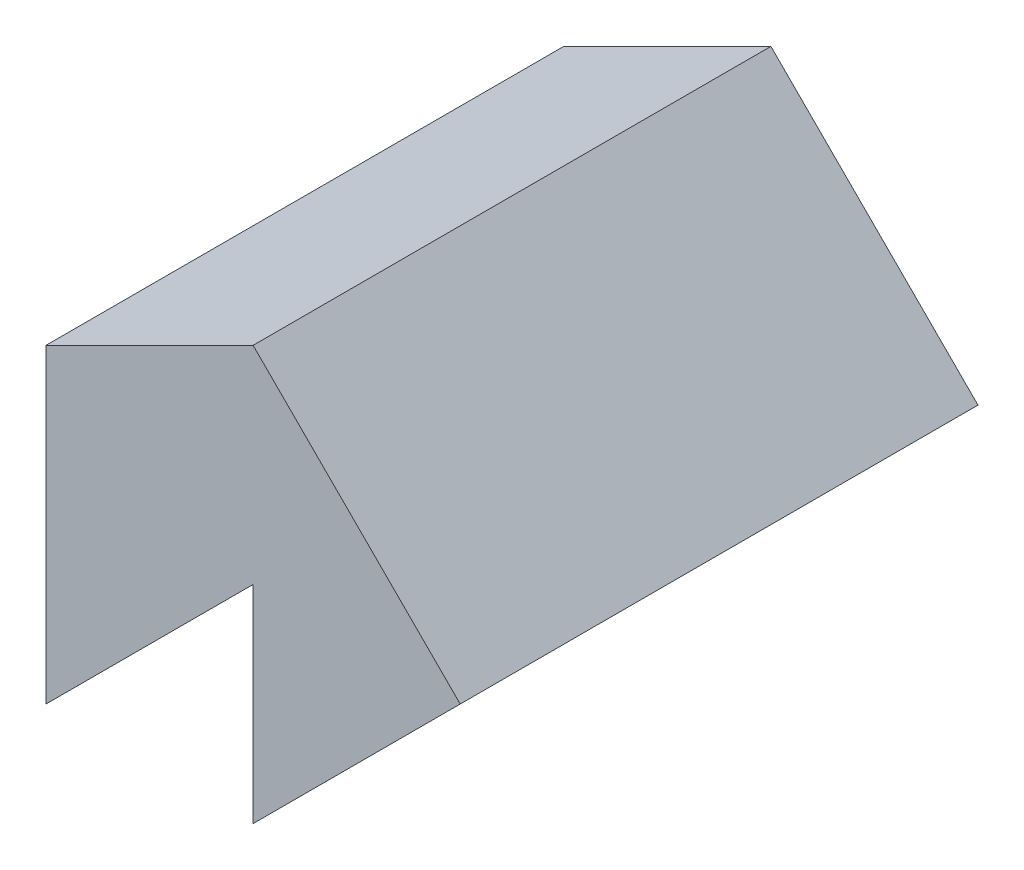
from build123d import *

# Parameters (mm, degrees)
BOSS_EXTRUDE1_DEPTH = 25


with BuildPart() as part:
    # Sketch1 → Boss-Extrude1 (new body)
    with BuildSketch(Plane.XY):
        Polygon((-10, 5), (0, 10), (10, 0), (0, -10), (0, 0), (-10, -10), align=None)
    extrude(amount=BOSS_EXTRUDE1_DEPTH)


solid = part.part
